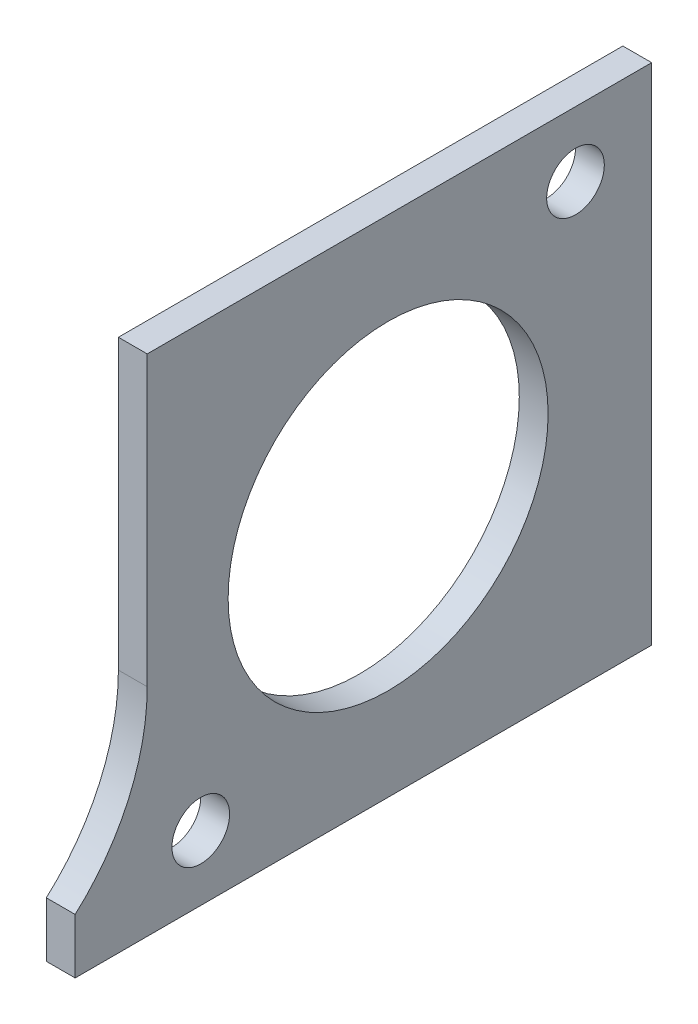
from build123d import *

# Parameters (mm, degrees)
SKETCH1_R           = 2
SKETCH1_R_2         = 11.1
BOSS_EXTRUDE1_DEPTH = 2


with BuildPart() as part:
    # Sketch1 → Boss-Extrude1 (new body)
    with BuildSketch(Plane(origin=(0, 0, 0), x_dir=(0, 0, -1), z_dir=(1, 0, 0))):
        with BuildLine():
            Line((14.978419371, -24.343119081), (14.978419371, 10.656880919))
            Line((14.978419371, 10.656880919), (-20.021580629, 10.656880919))
            Line((-20.021580629, 10.656880919), (-20.021580629, -9.343119081))
            ThreePointArc((-20.021580629, -9.343119081), (-21.328516692, -15.466843438), (-25.021580629, -20.523458968))
            Line((-25.021580629, -20.523458968), (-25.021580629, -24.343119081))
            Line((-25.021580629, -24.343119081), (14.978419371, -24.343119081))
        make_face()
        with Locations((9.692898744, 6.156880919)):
            Circle(SKETCH1_R, mode=Mode.SUBTRACT)
        with Locations((-16.307101256, -19.843119081)):
            Circle(SKETCH1_R, mode=Mode.SUBTRACT)
        with Locations((-3.307101256, -6.843119081)):
            Circle(SKETCH1_R_2, mode=Mode.SUBTRACT)
    extrude(amount=BOSS_EXTRUDE1_DEPTH)


solid = part.part
